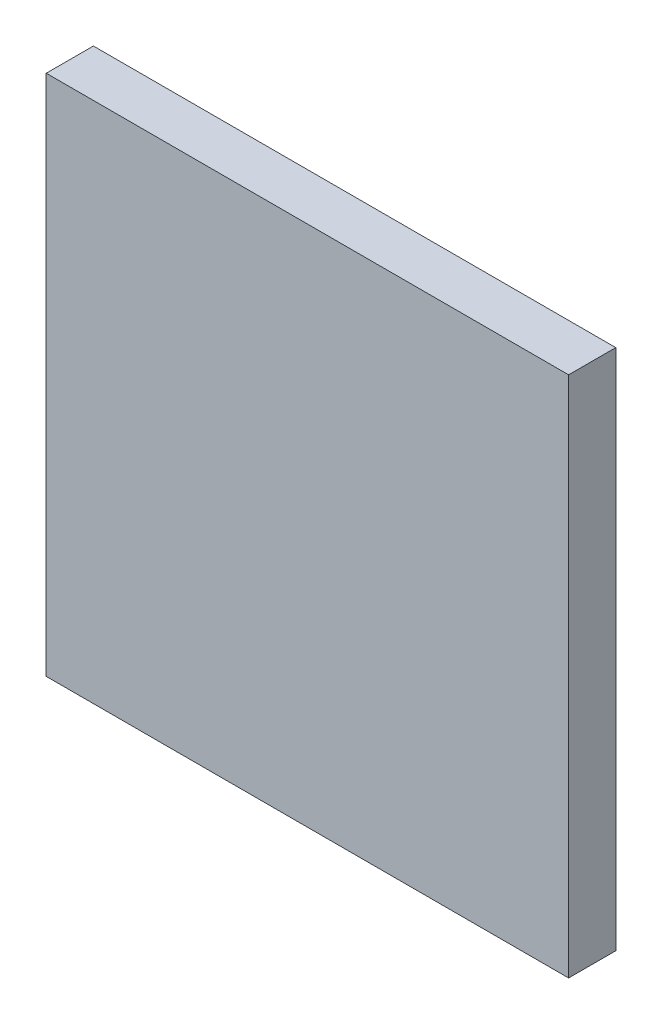
from build123d import *

# Parameters (mm, degrees)
SKETCH17_W     = 27.7
SKETCH17_H     = 27.7
FILTER_2_DEPTH = 2.5


with BuildPart() as part:
    # Sketch17 → filter 2 (new body)
    with BuildSketch(Plane.XY):
        with Locations((13.85, 13.85)):
            Rectangle(SKETCH17_W, SKETCH17_H)
    extrude(amount=FILTER_2_DEPTH)


solid = part.part
